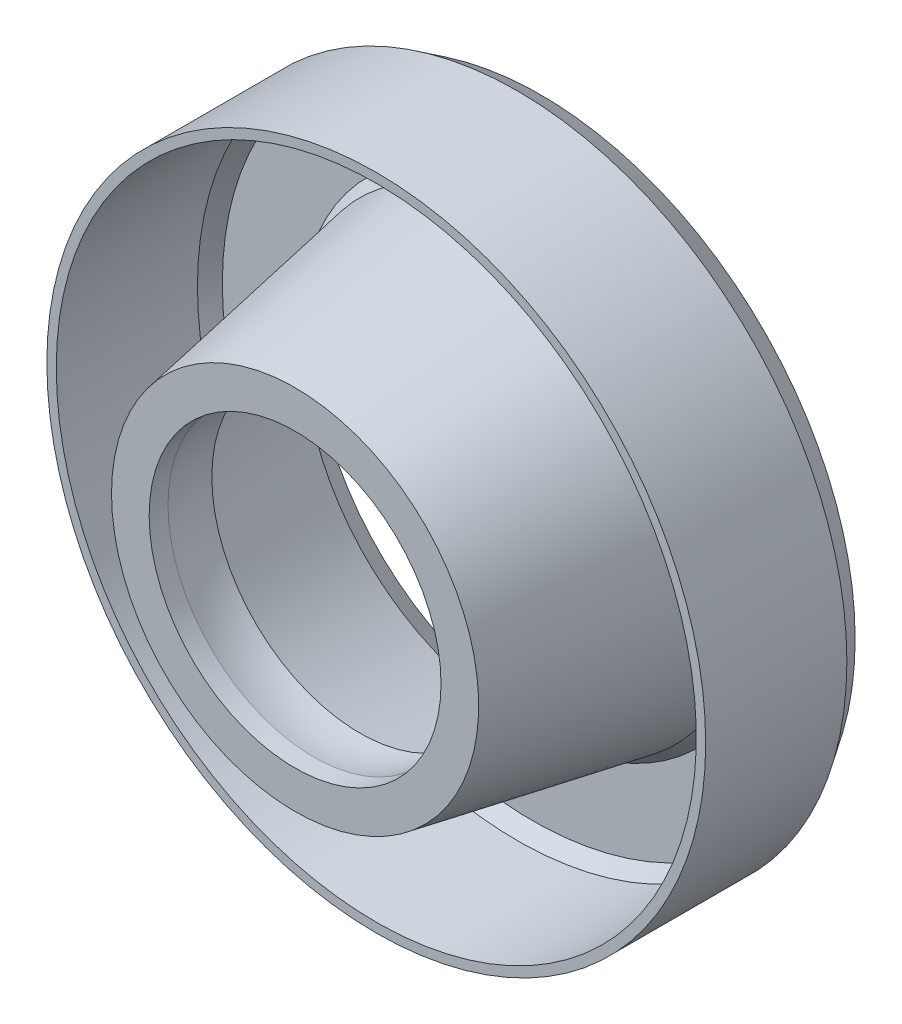
from build123d import *


with BuildPart() as part:
    # Sketch4 → Revolve1 (revolve)
    with BuildSketch(Plane(origin=(0, 0, 0), x_dir=(1, 0, 0), z_dir=(0, 1, 0))):
        with BuildLine():
            Line((-10.933333333, -10.966666667), (-9.933333333, -10.966666667))
            Line((-9.933333333, -10.966666667), (-9.933333333, 4.033333333))
            Line((-9.933333333, 4.033333333), (-8.890939345, 5.63491013))
            Line((-8.890939345, 5.63491013), (-0.702775901, 5.63491013))
            Line((-0.702775901, 5.63491013), (0.339618087, 4.033333333))
            Line((0.339618087, 4.033333333), (4.562176814, -19.592288305))
            Line((4.562176814, -19.592288305), (8.562176814, -19.592288305))
            Line((8.562176814, -19.592288305), (8.562176814, -17.592288305))
            ThreePointArc((8.562176814, -17.592288305), (8.256127983, -15.155893912), (8.330597185, -12.701481994))
            Line((8.330597185, -12.701481994), (4.330597185, -12.701481994))
            Line((4.330597185, -12.701481994), (1.339618087, 4.033333333))
            Line((1.339618087, 4.033333333), (-0.296857623, 6.547681609))
            Line((-0.296857623, 6.547681609), (-9.296857623, 6.547681609))
            Line((-9.296857623, 6.547681609), (-10.933333333, 4.033333333))
            Line((-10.933333333, 4.033333333), (-10.933333333, -10.966666667))
        make_face()
    revolve(axis=Axis((24.066666667, 0, -10.345988756), (0, 0, 1)))


solid = part.part
